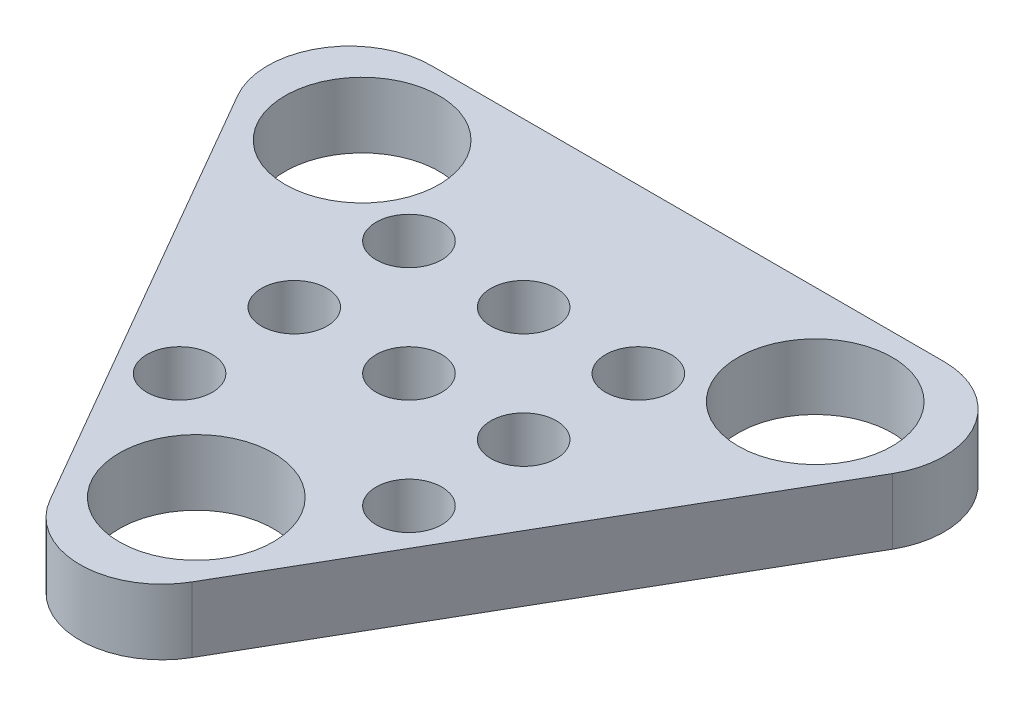
from build123d import *

# Parameters (mm, degrees)
SKETCH1_R      = 2.35
SKETCH1_R_2    = 1
EXTRUDE1_DEPTH = 2


with BuildPart() as part:
    # Sketch1 → Extrude1 (new body)
    with BuildSketch(Plane(origin=(0, 0, 0), x_dir=(1, 0, 0), z_dir=(0, 1, 0))):
        with BuildLine():
            Line((-5.186041147, 3.316192399), (2.637731834, -10.234979911))
            ThreePointArc((2.637731834, -10.234979911), (4.802795343, -11.484979911), (6.967858853, -10.234979911))
            Line((6.967858853, -10.234979911), (14.791631834, 3.316192399))
            ThreePointArc((14.791631834, 3.316192399), (14.791631834, 5.816192399), (12.626568324, 7.066192399))
            Line((12.626568324, 7.066192399), (-3.020977638, 7.066192399))
            ThreePointArc((-3.020977638, 7.066192399), (-5.186041147, 5.816192399), (-5.186041147, 3.316192399))
        make_face()
        with Locations((-2.110635714, 4.040606244)):
            Circle(SKETCH1_R, mode=Mode.SUBTRACT)
        with Locations((4.802795343, -7.933807601)):
            Circle(SKETCH1_R, mode=Mode.SUBTRACT)
        with Locations((11.7162264, 4.040606244)):
            Circle(SKETCH1_R, mode=Mode.SUBTRACT)
        with Locations((1.270334632, 2.088602105)):
            Circle(SKETCH1_R_2, mode=Mode.SUBTRACT)
        with Locations((4.770334632, 2.088602105)):
            Circle(SKETCH1_R_2, mode=Mode.SUBTRACT)
        with Locations((8.270334632, 2.088602105)):
            Circle(SKETCH1_R_2, mode=Mode.SUBTRACT)
        with Locations((1.270334632, -1.411397895)):
            Circle(SKETCH1_R_2, mode=Mode.SUBTRACT)
        with Locations((4.770334632, -1.411397895)):
            Circle(SKETCH1_R_2, mode=Mode.SUBTRACT)
        with Locations((8.270334632, -1.411397895)):
            Circle(SKETCH1_R_2, mode=Mode.SUBTRACT)
        with Locations((1.270334632, -4.911397895)):
            Circle(SKETCH1_R_2, mode=Mode.SUBTRACT)
        with Locations((8.270334632, -4.911397895)):
            Circle(SKETCH1_R_2, mode=Mode.SUBTRACT)
    extrude(amount=EXTRUDE1_DEPTH)


solid = part.part
